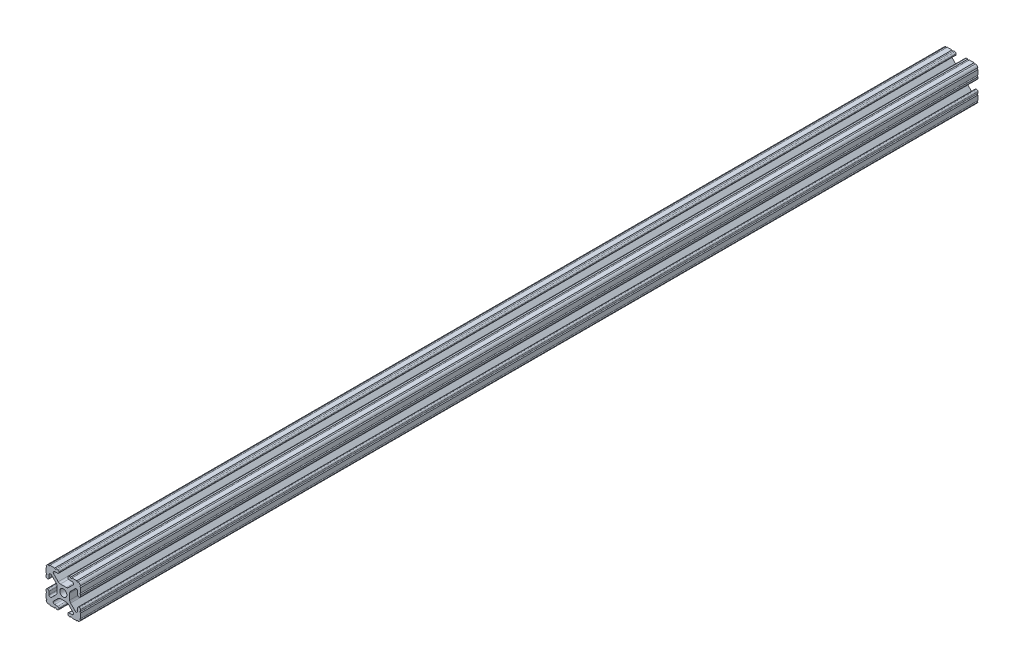
from build123d import *

# Parameters (mm, degrees)
BOSS_EXTRUDE1_DEPTH     = 328.6125
SKETCH5_R               = 0.55245
CUT_EXTRUDE1_DEPTH      = 329.6125
CUT_EXTRUDE1_DEPTH_BACK = 329.6125


with BuildPart() as part:
    # Sketch4 → Boss-Extrude1 (new body, symmetric)
    with BuildSketch(Plane.XY):
        with BuildLine():
            Line((4.190365, -12.7), (10.11729625, -12.7))
            ThreePointArc((10.11729625, -12.7), (11.943543585, -11.943543585), (12.7, -10.11729625))
            Line((12.7, -10.11729625), (12.7, -4.190365))
            ThreePointArc((12.7, -4.190365), (12.42492494, -3.52627506), (11.760835, -3.2512))
            Line((11.760835, -3.2512), (11.429365, -3.2512))
            ThreePointArc((11.429365, -3.2512), (10.76527506, -3.52627506), (10.4902, -4.190365))
            Line((10.4902, -4.190365), (10.4902, -6.348478019))
            ThreePointArc((10.4902, -6.348478019), (9.830707141, -7.335478831), (8.666460301, -7.103895736))
            Line((8.666460301, -7.103895736), (5.299899128, -3.737334563))
            ThreePointArc((5.299899128, -3.737334563), (4.817571085, -3.015479634), (4.6482, -2.16399369))
            Line((4.6482, -2.16399369), (4.6482, 0))
            Line((4.6482, 0), (2.6035, 0))
            ThreePointArc((2.6035, 0), (1.840952505, -1.840952505), (0, -2.6035))
            Line((0, -2.6035), (0, -4.6482))
            Line((0, -4.6482), (2.16399369, -4.6482))
            ThreePointArc((2.16399369, -4.6482), (3.015479634, -4.817571085), (3.737334563, -5.299899128))
            Line((3.737334563, -5.299899128), (7.103895736, -8.666460301))
            ThreePointArc((7.103895736, -8.666460301), (7.335478831, -9.830707141), (6.348478019, -10.4902))
            Line((6.348478019, -10.4902), (4.190365, -10.4902))
            ThreePointArc((4.190365, -10.4902), (3.52627506, -10.76527506), (3.2512, -11.429365))
            Line((3.2512, -11.429365), (3.2512, -11.760835))
            ThreePointArc((3.2512, -11.760835), (3.52627506, -12.42492494), (4.190365, -12.7))
        make_face()
    extrude(amount=BOSS_EXTRUDE1_DEPTH, both=True)

    # Sketch5 → Cut-Extrude1 (cut, two sides)
    with BuildSketch(Plane.XY) as cut_extrude1_sk:
        with Locations((10.356153152, -12.7)):
            Circle(SKETCH5_R)
        with Locations((5.796028019, -12.7)):
            Circle(SKETCH5_R)
        with Locations((12.7, -10.356153152)):
            Circle(SKETCH5_R)
        with Locations((12.7, -5.796028019)):
            Circle(SKETCH5_R)
    extrude(amount=CUT_EXTRUDE1_DEPTH, mode=Mode.SUBTRACT)
    extrude(cut_extrude1_sk.sketch, amount=-CUT_EXTRUDE1_DEPTH_BACK, mode=Mode.SUBTRACT)

    # Mirror1: part across plane


with BuildPart() as part_1:
    add(part.part)
    add(part.part.mirror(Plane(origin=(0, 0, 0), x_dir=(0, 0, 1), z_dir=(1, 0, 0))))

    # Mirror2: part across plane


with BuildPart() as part_2:
    add(part_1.part)
    add(part_1.part.mirror(Plane.ZX))


solid = part_2.part
